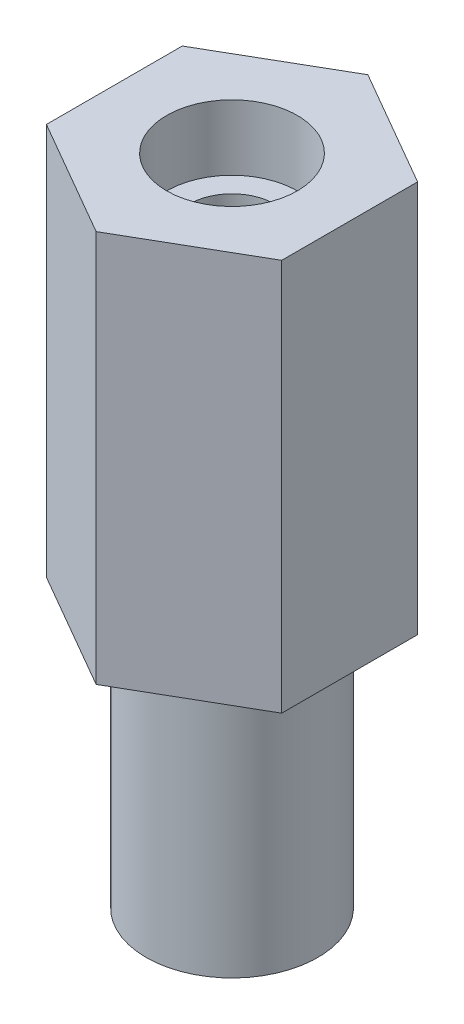
from build123d import *

# Parameters (mm, degrees)
SKETCH_1_R          = 3.264424224
EXTRUDE_1_DEPTH     = 50
SKETCH_2_OUTSIDE_W  = 31.412
SKETCH_2_OUTSIDE_H  = 34.196
SKETCH_2_OUTSIDE_R  = 6.567936001
CUT_EXTRUDE_1_DEPTH = 20
SKETCH_3_R          = 5
CUT_EXTRUDE_2_DEPTH = 5


with BuildPart() as part:
    # Эскиз1 → Бобышка-Вытянуть1 (new body)
    with BuildSketch(Plane(origin=(0, 0, 0), x_dir=(1, 0, 0), z_dir=(0, 1, 0))):
        Polygon((0, 10.392304845), (-9, 5.196152423), (-9, -5.196152423), (0, -10.392304845), (9, -5.196152423), (9, 5.196152423), align=None)
        Circle(SKETCH_1_R, mode=Mode.SUBTRACT)
    extrude(amount=EXTRUDE_1_DEPTH)

    # Эскиз2 outside → Вырез-Вытянуть1 (cut)
    with BuildSketch(Plane.XZ):
        Rectangle(SKETCH_2_OUTSIDE_W, SKETCH_2_OUTSIDE_H)
        Circle(SKETCH_2_OUTSIDE_R, mode=Mode.SUBTRACT)
    extrude(amount=-CUT_EXTRUDE_1_DEPTH, mode=Mode.SUBTRACT)

    # Эскиз3 → Вырез-Вытянуть2 (cut)
    with BuildSketch(Plane(origin=(0, 50, 0), x_dir=(1, 0, 0), z_dir=(0, 1, 0))):
        Circle(SKETCH_3_R)
    extrude(amount=-CUT_EXTRUDE_2_DEPTH, mode=Mode.SUBTRACT)


solid = part.part
